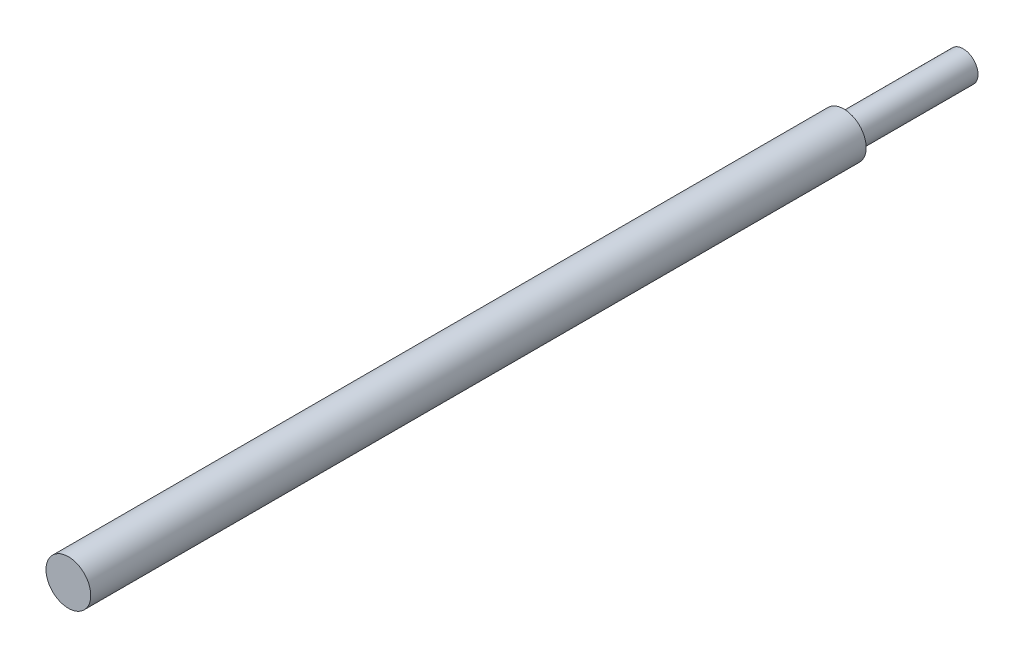
from build123d import *

# Parameters (mm, degrees)
SKETCH_1_R          = 7.5
EXTRUDE_1_DEPTH     = 300
SKETCH_2_OUTSIDE_W  = 77.15
SKETCH_2_OUTSIDE_H  = 77.15
SKETCH_2_OUTSIDE_R  = 5
CUT_EXTRUDE_1_DEPTH = 40


with BuildPart() as part:
    # 草图1 → 凸台-拉伸1 (new body)
    with BuildSketch(Plane.XY):
        Circle(SKETCH_1_R)
    extrude(amount=EXTRUDE_1_DEPTH)

    # 草图2 outside → 切除-拉伸1 (cut)
    with BuildSketch(Plane(origin=(0, 0, 0), x_dir=(-1, 0, 0), z_dir=(0, 0, -1))):
        Rectangle(SKETCH_2_OUTSIDE_W, SKETCH_2_OUTSIDE_H)
        Circle(SKETCH_2_OUTSIDE_R, mode=Mode.SUBTRACT)
    extrude(amount=-CUT_EXTRUDE_1_DEPTH, mode=Mode.SUBTRACT)


solid = part.part
